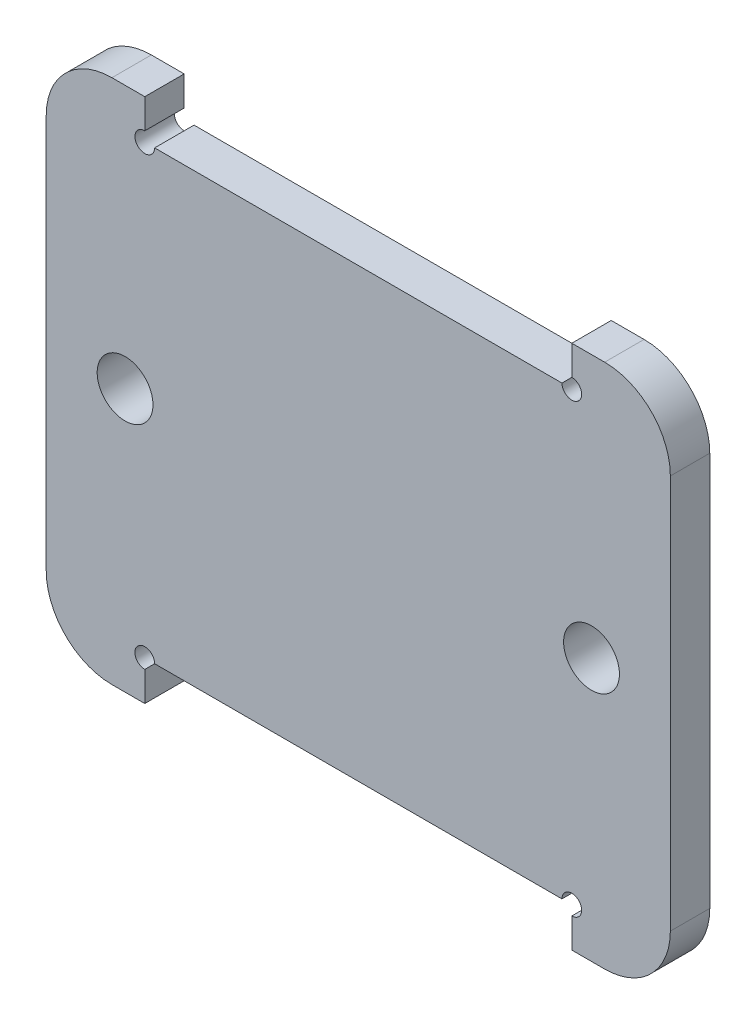
from build123d import *

# Parameters (mm, degrees)
SKETCH1_R           = 4.25
BOSS_EXTRUDE1_DEPTH = 6
SKETCH2_R           = 1.5
CUT_EXTRUDE1_DEPTH  = 7


with BuildPart() as part:
    # Sketch1 → Boss-Extrude1 (new body)
    with BuildSketch(Plane.XY):
        with BuildLine():
            Line((-380, 94), (-315, 94))
            Line((-315, 94), (-315, 100))
            Line((-315, 100), (-310, 100))
            ThreePointArc((-310, 100), (-302.928932188, 97.071067812), (-300, 90))
            Line((-300, 90), (-300, 30))
            ThreePointArc((-300, 30), (-302.928932188, 22.928932188), (-310, 20))
            Line((-310, 20), (-315, 20))
            Line((-315, 20), (-315, 26))
            Line((-315, 26), (-380, 26))
            Line((-380, 26), (-380, 20))
            Line((-380, 20), (-385, 20))
            ThreePointArc((-385, 20), (-392.071067812, 22.928932188), (-395, 30))
            Line((-395, 30), (-395, 90))
            ThreePointArc((-395, 90), (-392.071067812, 97.071067812), (-385, 100))
            Line((-385, 100), (-380, 100))
            Line((-380, 100), (-380, 94))
        make_face()
        with Locations((-312, 60)):
            Circle(SKETCH1_R, mode=Mode.SUBTRACT)
        with Locations((-383, 60)):
            Circle(SKETCH1_R, mode=Mode.SUBTRACT)
    extrude(amount=BOSS_EXTRUDE1_DEPTH)

    # Sketch2 → Cut-Extrude1 (cut, through all)
    with BuildSketch(Plane.XY.offset(6)):
        with Locations((-380, 26)):
            Circle(SKETCH2_R)
        with Locations((-315, 26)):
            Circle(SKETCH2_R)
        with Locations((-380, 94)):
            Circle(SKETCH2_R)
        with Locations((-315, 94)):
            Circle(SKETCH2_R)
    extrude(amount=-CUT_EXTRUDE1_DEPTH, mode=Mode.SUBTRACT)


solid = part.part
